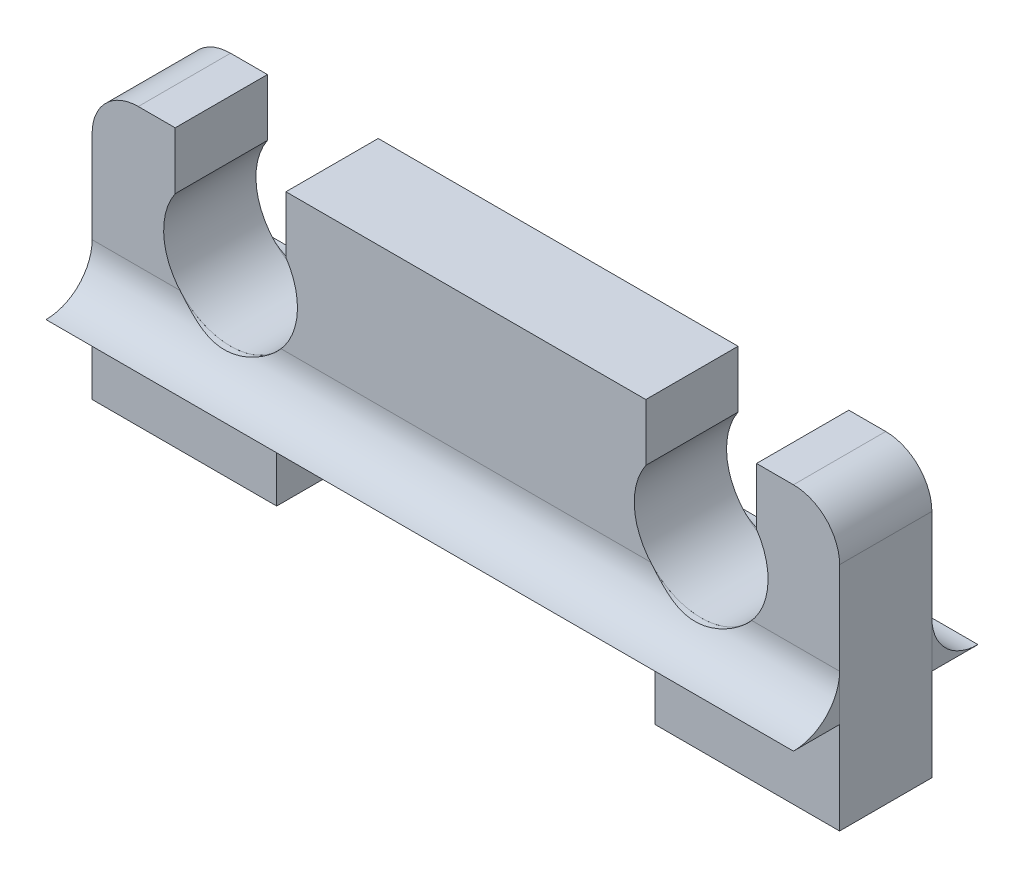
from build123d import *

# Parameters (mm, degrees)
BOSS_EXTRUDE1_DEPTH     = 2
BOSS_EXTRUDE2_DEPTH     = 16.2
BOSS_EXTRUDE2_2_DEPTH   = 16.2
SKETCH3_W               = 4
SKETCH3_H               = 2
CUT_EXTRUDE1_DEPTH      = 4
CUT_EXTRUDE4_START      = -1.236059
SKETCH5_W               = 2.4
SKETCH5_H               = 2
CUT_EXTRUDE4_DEPTH      = 1.236059
SKETCH8_R               = 1.45
CUT_EXTRUDE6_DEPTH      = 3
CUT_EXTRUDE6_DEPTH_BACK = 3


with BuildPart() as part:
    # Sketch1 → Boss-Extrude1 (new body)
    with BuildSketch(Plane.XY):
        with BuildLine():
            Line((4, 8), (12.2, 8))
            Line((12.2, 8), (12.2, 7))
            ThreePointArc((12.2, 7), (13.2, 4.5), (14.2, 7))
            Line((14.2, 7), (14.2, 8))
            Line((14.2, 8), (15.2, 8))
            ThreePointArc((15.2, 8), (15.907106781, 7.707106781), (16.2, 7))
            Line((16.2, 7), (16.2, 0))
            Line((16.2, 0), (12.2, 0))
            Line((12.2, 0), (12.2, 4))
            Line((12.2, 4), (4, 4))
            Line((4, 4), (4, 0))
            Line((4, 0), (0, 0))
            Line((0, 0), (0, 7))
            ThreePointArc((0, 7), (0.292893219, 7.707106781), (1, 8))
            Line((1, 8), (2, 8))
            Line((2, 8), (2, 7))
            ThreePointArc((2, 7), (3, 4.5), (4, 7))
            Line((4, 7), (4, 8))
        make_face()
    extrude(amount=BOSS_EXTRUDE1_DEPTH)

    # Sketch3 → Cut-Extrude1 (cut, through all)
    with BuildSketch(Plane.XY.offset(2)):
        with Locations((2, 1)):
            Rectangle(SKETCH3_W, SKETCH3_H)
        with Locations((14.2, 1)):
            Rectangle(SKETCH3_W, SKETCH3_H)
    extrude(amount=-CUT_EXTRUDE1_DEPTH, mode=Mode.SUBTRACT)

    # Sketch5 → Cut-Extrude4 (cut)
    with BuildSketch(Plane(origin=(0, 8, 0), x_dir=(1, 0, 0), z_dir=(0, 1, 0)).offset(CUT_EXTRUDE4_START)):
        with Locations((3, -1)):
            Rectangle(SKETCH5_W, SKETCH5_H)
        with Locations((13.2, -1)):
            Rectangle(SKETCH5_W, SKETCH5_H)
    extrude(amount=CUT_EXTRUDE4_DEPTH, mode=Mode.SUBTRACT)


with BuildPart() as body_2:
    # Sketch2 → Boss-Extrude2 (new body)
    with BuildSketch(Plane.ZY):
        with BuildLine():
            Line((2, 4), (2, 5))
            ThreePointArc((2, 5), (2.292893219, 4.292893219), (3, 4))
            Line((3, 4), (2, 4))
        make_face()
    extrude(amount=-BOSS_EXTRUDE2_DEPTH)


with BuildPart() as body_3:
    # Sketch2 → Boss-Extrude2 2 (new body)
    with BuildSketch(Plane.ZY):
        with BuildLine():
            Line((0, 4), (-1, 4))
            ThreePointArc((-1, 4), (-0.292893219, 4.292893219), (0, 5))
            Line((0, 5), (0, 4))
        make_face()
    extrude(amount=-BOSS_EXTRUDE2_2_DEPTH)


with BuildPart() as cut_extrude6_tool:
    # Sketch8 → Cut-Extrude6 (new body, two sides)
    with BuildSketch(Plane.XY.offset(1)) as cut_extrude6_sk:
        with Locations((3, 5.95)):
            Circle(SKETCH8_R)
        with Locations((13.2, 5.95)):
            Circle(SKETCH8_R)
    extrude(amount=CUT_EXTRUDE6_DEPTH)
    extrude(cut_extrude6_sk.sketch, amount=-CUT_EXTRUDE6_DEPTH_BACK)


with BuildPart() as body_2_1:
    add(body_2.part)

    # Cut-Extrude6: cut by cut_extrude6_tool
    add(cut_extrude6_tool.part, mode=Mode.SUBTRACT)


with BuildPart() as body_3_1:
    add(body_3.part)

    # Cut-Extrude6: cut by cut_extrude6_tool
    add(cut_extrude6_tool.part, mode=Mode.SUBTRACT)


solid = Compound([part.part, body_2_1.part, body_3_1.part])
